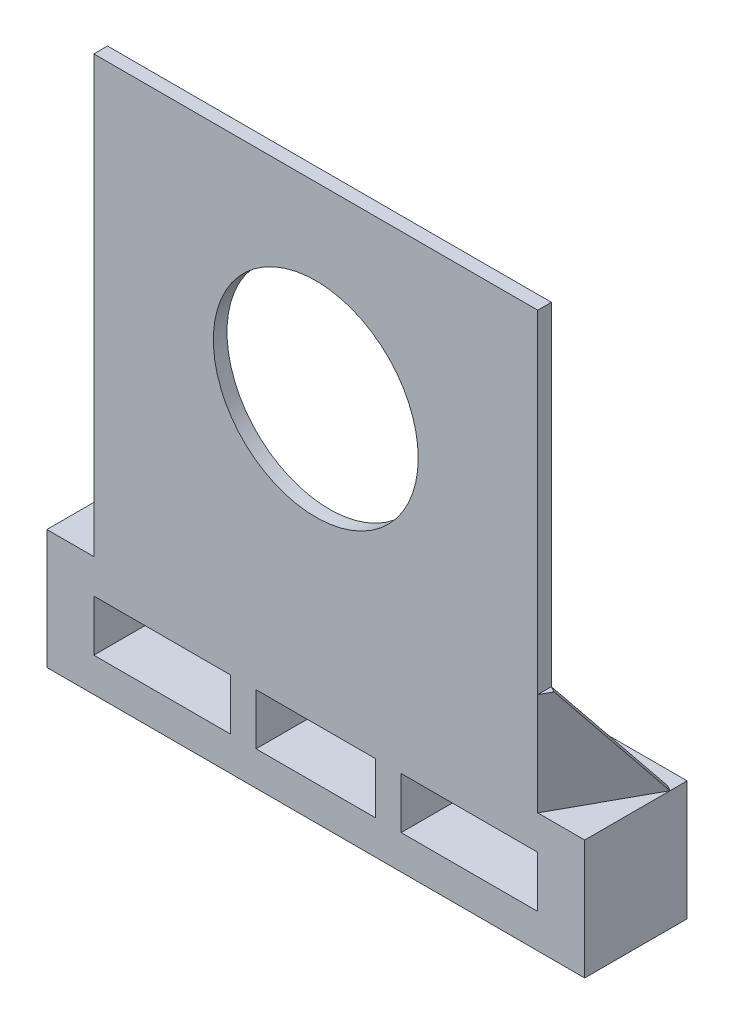
from build123d import *

# Parameters (mm, degrees)
SKETCH1_W           = 260
SKETCH1_H           = 255
SKETCH1_R           = 60
BOSS_EXTRUDE1_DEPTH = 8
SKETCH2_W           = 315
SKETCH2_H           = 70
SKETCH2_W_2         = 70
SKETCH2_H_2         = 30
SKETCH2_W_3         = 80
SKETCH2_W_4         = 80.179391324
BOSS_EXTRUDE2_DEPTH = 60
BOSS_EXTRUDE3_DEPTH = 60
CUT_EXTRUDE2_DEPTH  = 281.827198731
CUT_EXTRUDE3_DEPTH  = 281.827198731


with BuildPart() as part:
    # Sketch1 → Boss-Extrude1 (new body)
    with BuildSketch(Plane.XY):
        Rectangle(SKETCH1_W, SKETCH1_H)
        with Locations((0, 17.5)):
            Circle(SKETCH1_R, mode=Mode.SUBTRACT)
    extrude(amount=-BOSS_EXTRUDE1_DEPTH)

    # Sketch2 → Boss-Extrude2 (add)
    with BuildSketch(Plane.XY):
        with Locations((0, -162.5)):
            Rectangle(SKETCH2_W, SKETCH2_H)
        with Locations((0, -162.5)):
            Rectangle(SKETCH2_W_2, SKETCH2_H_2, mode=Mode.SUBTRACT)
        with Locations((90, -162.5)):
            Rectangle(SKETCH2_W_3, SKETCH2_H_2, mode=Mode.SUBTRACT)
        with Locations((-90.089695662, -162.5)):
            Rectangle(SKETCH2_W_4, SKETCH2_H_2, mode=Mode.SUBTRACT)
    extrude(amount=-BOSS_EXTRUDE2_DEPTH)

    # Sketch3 → Boss-Extrude3 (add)
    with BuildSketch(Plane(origin=(0, -127.5, 0), x_dir=(1, 0, 0), z_dir=(0, 1, 0))):
        Polygon((130, 0), (157.5, 50), (154.121880998, 51.857965451), (130, 8), align=None)
    extrude(amount=BOSS_EXTRUDE3_DEPTH)

    # Mirror1: part across plane


with BuildPart() as part_1:
    add(part.part)
    add(part.part.mirror(Plane(origin=(0, 0, 0), x_dir=(0, 0, 1), z_dir=(1, 0, 0))))

    # Sketch6 → Cut-Extrude2 (cut, through all)
    with BuildSketch(Plane(origin=(99.80806142, 0, 54.894433781), x_dir=(0.48191875, 0, -0.876215909), z_dir=(0.876215909, 0, 0.48191875))):
        Polygon((69.65916474, -67.5), (119.712998523, -127.5), (119.712998523, -67.5), align=None)
    extrude(amount=-CUT_EXTRUDE2_DEPTH, mode=Mode.SUBTRACT)

    # Sketch7 → Cut-Extrude3 (cut, through all)
    with BuildSketch(Plane(origin=(-99.80806142, 0, 54.894433781), x_dir=(0.48191875, 0, 0.876215909), z_dir=(-0.876215909, 0, 0.48191875))):
        Polygon((-69.65916474, -67.5), (-119.712998523, -127.5), (-119.712998523, -67.5), align=None)
    extrude(amount=-CUT_EXTRUDE3_DEPTH, mode=Mode.SUBTRACT)


solid = part_1.part
